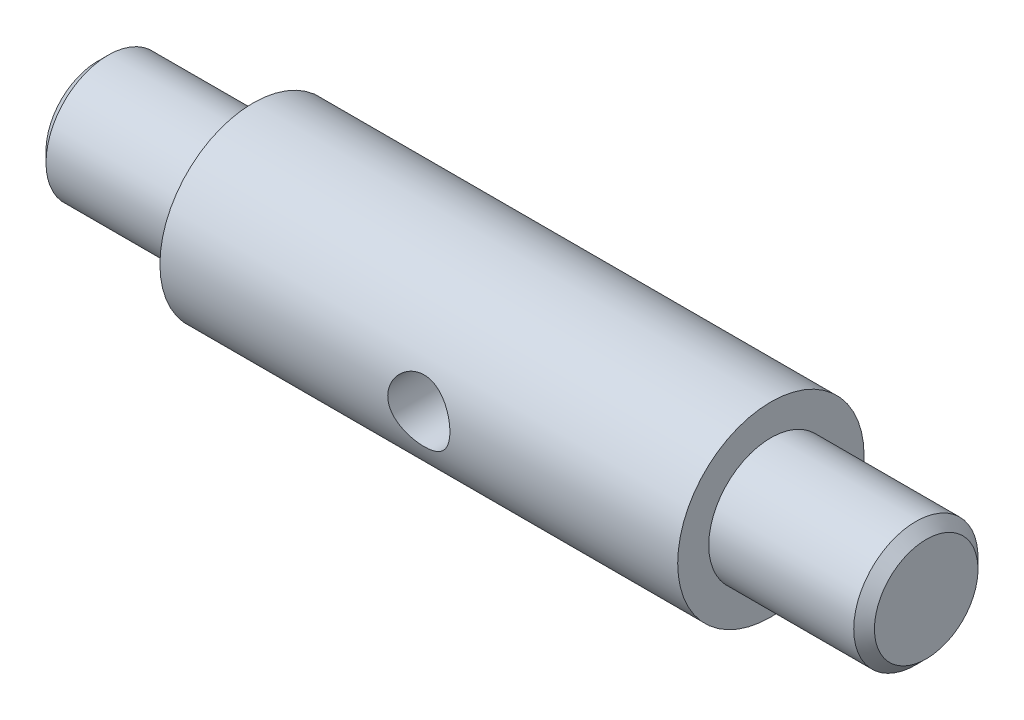
from build123d import *

# Parameters (mm, degrees)
SKETCH2_R                    = 3
CUT_EXTRUDE1_DEPTH           = 10
CUT_EXTRUDE1_DEPTH_BACK      = 10
CHAMFER1_SIZE                = 1
F_6_0_6_DIAMETER_HOLE1_D     = 6
F_6_0_6_DIAMETER_HOLE1_DEPTH = 45
F_6_0_6_DIAMETER_HOLE1_TIP   = 1.802581857


with BuildPart() as part:
    # Sketch1 → Revolve1 (revolve)
    with BuildSketch(Plane.XY):
        Polygon((0, 0), (80, 0), (80, 6), (65, 6), (65, 9), (15, 9), (15, 6), (0, 6), align=None)
    revolve(axis=Axis((0, 0, 0), (1, 0, 0)))

    # Sketch2 → Cut-Extrude1 (cut, two sides)
    with BuildSketch(Plane.XY) as cut_extrude1_sk:
        with Locations((40, 0)):
            Circle(SKETCH2_R)
    extrude(amount=CUT_EXTRUDE1_DEPTH, mode=Mode.SUBTRACT)
    extrude(cut_extrude1_sk.sketch, amount=-CUT_EXTRUDE1_DEPTH_BACK, mode=Mode.SUBTRACT)

    # Chamfer1
    chamfer1_edges = [part.edges().sort_by_distance(p)[0] for p in [
        (0, -6, 0),
        (80, -6, 0),
    ]]
    chamfer(chamfer1_edges, length=CHAMFER1_SIZE)

    # Ø6.0 (6) Diameter Hole1
    with Locations(Plane.ZY):
        with Locations((0, 0)):
            Hole(F_6_0_6_DIAMETER_HOLE1_D / 2, depth=F_6_0_6_DIAMETER_HOLE1_DEPTH)
            with Locations((0, 0, -(F_6_0_6_DIAMETER_HOLE1_DEPTH + F_6_0_6_DIAMETER_HOLE1_TIP / 2))):  # 118° drill point
                Cone(0, F_6_0_6_DIAMETER_HOLE1_D / 2, F_6_0_6_DIAMETER_HOLE1_TIP, mode=Mode.SUBTRACT)


solid = part.part
